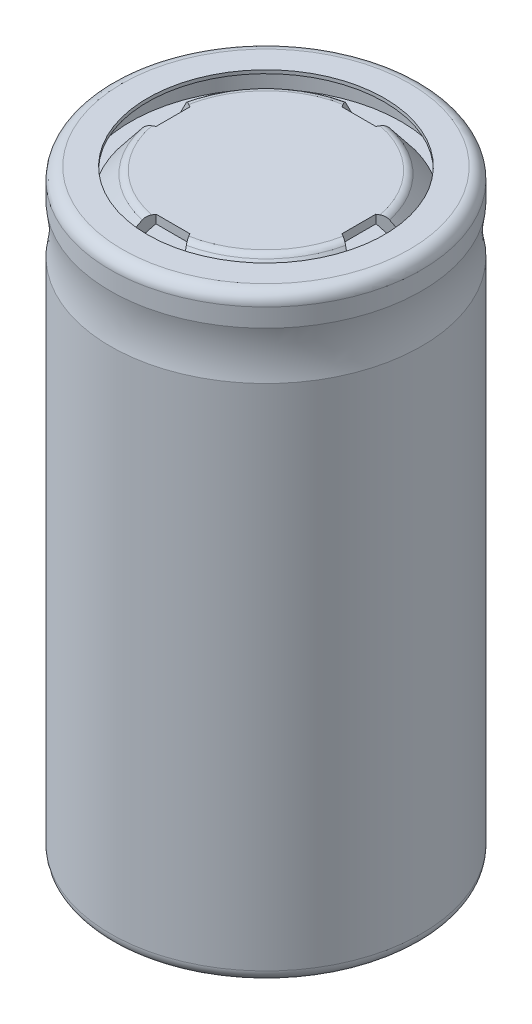
from build123d import *

# Parameters (mm, degrees)
CUT_EXTRUDE_1_DEPTH      = 1
CUT_EXTRUDE_1_DEPTH_BACK = 1.501485988


with BuildPart() as part:
    # Эскиз1 → Повернуть1 (revolve)
    with BuildSketch(Plane.XY):
        with BuildLine():
            Line((0, 0.5), (0, 0))
            Line((0, 0), (8.5, 0))
            ThreePointArc((8.5, 0), (8.853553391, 0.146446609), (9, 0.5))
            Line((9, 0.5), (9, 30.587272326))
            ThreePointArc((9, 30.587272326), (8.90824829, 30.875947461), (8.666666667, 31.058676847))
            ThreePointArc((8.666666667, 31.058676847), (8, 32.001485888), (8.666666667, 32.94429493))
            ThreePointArc((8.666666667, 32.94429493), (8.90824829, 33.127024316), (9, 33.415699451))
            Line((9, 33.415699451), (9, 34.5))
            ThreePointArc((9, 34.5), (8.498514112, 35.001485888), (7.997028223, 34.5))
            Line((7.997028223, 34.5), (7.997028223, 33.5))
            Line((7.997028223, 33.5), (7.2, 33.5))
            Line((7.2, 33.5), (6.150171734, 34.813585272))
            ThreePointArc((6.150171734, 34.813585272), (5.976233912, 34.95205247), (5.759462711, 35.00142632))
            Line((5.759462711, 35.00142632), (0, 35))
            Line((0, 35), (0, 34.5))
            Line((0, 34.5), (5.608751555, 34.5))
            Line((5.608751555, 34.5), (6.7, 33.5))
            Line((6.7, 33.5), (0, 33.5))
            Line((0, 33.5), (0, 33))
            Line((0, 33), (8.2, 33))
            Line((8.2, 33), (8.2, 33.5))
            Line((8.2, 33.5), (8.498514112, 33.5))
            Line((8.498514112, 33.5), (8.498514112, 33.415173231))
            ThreePointArc((8.498514112, 33.415173231), (8.406914027, 33.126712646), (8.165676074, 32.943944117))
            ThreePointArc((8.165676074, 32.943944117), (7.500000138, 32.00096045), (8.166666667, 31.058676847))
            ThreePointArc((8.166666667, 31.058676847), (8.40824829, 30.875947461), (8.5, 30.587272326))
            Line((8.5, 30.587272326), (8.5, 0.5))
            Line((8.5, 0.5), (0, 0.5))
        make_face()
    revolve(axis=Axis((0, 0, 0), (0, 1, 0)))

    # Эскиз2 → Вырез-Вытянуть1 (cut, two sides)
    with BuildSketch(Plane.XZ.offset(-34.5)) as cut_extrude_1_sk:
        Polygon((-1, -5.495703298), (1, -5.495703298), (2, -7.2), (-2, -7.2), align=None)
        Polygon((-5.495703298, 1), (-5.495703298, -1), (-7.2, -2), (-7.2, 2), align=None)
        Polygon((1, 5.495703298), (-1, 5.495703298), (-2, 7.2), (2, 7.2), align=None)
        Polygon((5.495703298, -1), (5.495703298, 1), (7.2, 2), (7.2, -2), align=None)
    extrude(amount=CUT_EXTRUDE_1_DEPTH, mode=Mode.SUBTRACT)
    extrude(cut_extrude_1_sk.sketch, amount=-CUT_EXTRUDE_1_DEPTH_BACK, mode=Mode.SUBTRACT)


with BuildPart() as body_2:
    # Эскиз3 → Повернуть4 (revolve)
    with BuildSketch(Plane.XY):
        with BuildLine():
            Line((8.497664073, 0), (7, 0))
            Line((7, 0), (7, -0.2))
            Line((7, -0.2), (8.5, -0.2))
            ThreePointArc((8.5, -0.2), (8.994974747, 0.005025253), (9.2, 0.5))
            Line((9.2, 0.5), (9.2, 30.587272326))
            add(Edge.make_bspline(
                [(9.2, 33.416313782), (8.901392965, 31.953947415), (9.2, 30.587272326)],
                knots=[0, 0, 0, 0.679954534, 0.679954534, 0.679954534], degree=2))
            Line((9.2, 33.416313782), (9.2, 34.5))
            ThreePointArc((9.2, 34.5), (8.99453954, 34.996025429), (8.498514112, 35.201485888))
            Line((8.498514112, 35.201485888), (7, 35.201485888))
            Line((7, 35.201485888), (7, 35.001485888))
            Line((7, 35.001485888), (8.496178619, 35.00148045))
            ThreePointArc((8.496178619, 35.00148045), (8.852291499, 34.855428835), (9, 34.5))
            Line((9, 34.5), (9, 33.415699451))
            add(Edge.make_bspline(
                [(9, 33.415699451), (8.697080045, 31.944299731), (9, 30.587272326)],
                knots=[0, 0, 0, 0.587527579, 0.587527579, 0.587527579], degree=2))
            Line((9, 30.587272326), (9, 0.5))
            ThreePointArc((9, 0.5), (8.885768464, 0.18190773), (8.595269231, 0.009160135))
            Line((8.595269231, 0.009160135), (8.497664073, 0))
        make_face()
    revolve(axis=Axis((0, -2.74002086, 0), (0, 1, 0)))


solid = Compound([part.part, body_2.part])
